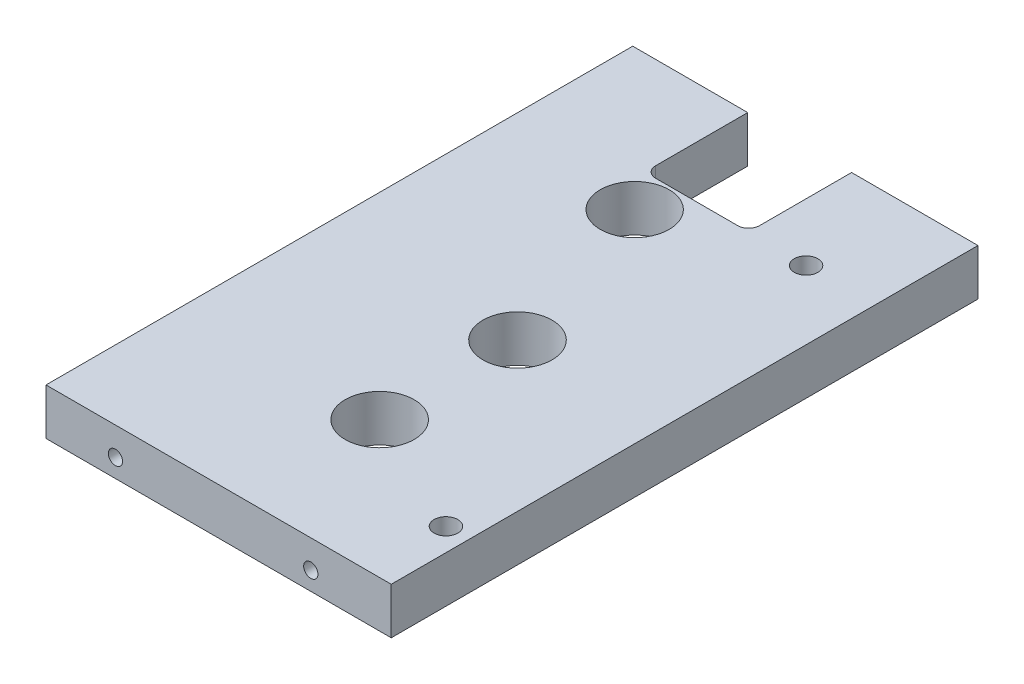
from build123d import *

# Parameters (mm, degrees)
SKETCH1_W           = 95.25
SKETCH1_H           = 12.8
BOSS_EXTRUDE1_DEPTH = 161.88
SKETCH1_3_R         = 3.1
CUT_EXTRUDE1_DEPTH  = 20.2
SKETCH1_4_R         = 2.395
CUT_EXTRUDE2_DEPTH  = 21.5
CUT_EXTRUDE3_REACH  = 14.8
SKETCH2_R           = 9.525
SKETCH2_R_2         = 3.265
SKETCH3_R           = 3.265
SKETCH3_R_2         = 9.525
CUT_EXTRUDE4_DEPTH  = 3.32
CUT_EXTRUDE5_START  = -17.25
SKETCH4_R           = 1.965
CUT_EXTRUDE5_DEPTH  = 17.25
SKETCH6_R           = 9.5
CUT_EXTRUDE6_DEPTH  = 13.8000001


with BuildPart() as part:
    # Sketch1 → Boss-Extrude1 (new body)
    with BuildSketch(Plane.XY):
        with Locations((-282.25, -82.5)):
            Rectangle(SKETCH1_W, SKETCH1_H)
    extrude(amount=BOSS_EXTRUDE1_DEPTH)

    # Sketch1_3 → Cut-Extrude1 (cut)
    with BuildSketch(Plane.XY):
        with Locations((-308, -82.5)):
            Circle(SKETCH1_3_R)
        with Locations((-257.2, -82.5)):
            Circle(SKETCH1_3_R)
    extrude(amount=CUT_EXTRUDE1_DEPTH, mode=Mode.SUBTRACT)

    # Sketch1_4 → Cut-Extrude2 (cut)
    with BuildSketch(Plane.XY):
        with Locations((-320.5, -82.5)):
            Circle(SKETCH1_4_R)
        with Locations((-244.2, -82.5)):
            Circle(SKETCH1_4_R)
    extrude(amount=CUT_EXTRUDE2_DEPTH, mode=Mode.SUBTRACT)

    # Sketch2 → Cut-Extrude3 (cut, up to next)
    with BuildSketch(Plane(origin=(0, -76.1, 0), x_dir=(-1, 0, 0), z_dir=(0, 1, 0)), mode=Mode.PRIVATE) as cut_extrude3_sk1:
        with Locations((275.57, 86.105)):
            Circle(SKETCH2_R)
    cut_extrude3_tool1 = extrude(cut_extrude3_sk1.sketch, amount=-CUT_EXTRUDE3_REACH, mode=Mode.PRIVATE) & part.part
    add(cut_extrude3_tool1.solids().sort_by_distance((-275.57, -76.1, 86.105))[0], mode=Mode.SUBTRACT)
    # Sketch2 → Cut-Extrude3 (cut, up to next)
    with BuildSketch(Plane(origin=(0, -76.1, 0), x_dir=(-1, 0, 0), z_dir=(0, 1, 0)), mode=Mode.PRIVATE) as cut_extrude3_sk2:
        with Locations((275.57, 124.135)):
            Circle(SKETCH2_R)
    cut_extrude3_tool2 = extrude(cut_extrude3_sk2.sketch, amount=-CUT_EXTRUDE3_REACH, mode=Mode.PRIVATE) & part.part
    add(cut_extrude3_tool2.solids().sort_by_distance((-275.57, -76.1, 124.135))[0], mode=Mode.SUBTRACT)
    # Sketch2 → Cut-Extrude3 (cut, up to next)
    with BuildSketch(Plane(origin=(0, -76.1, 0), x_dir=(-1, 0, 0), z_dir=(0, 1, 0)), mode=Mode.PRIVATE) as cut_extrude3_sk3:
        with Locations((253.55, 28.505)):
            Circle(SKETCH2_R_2)
    cut_extrude3_tool3 = extrude(cut_extrude3_sk3.sketch, amount=-CUT_EXTRUDE3_REACH, mode=Mode.PRIVATE) & part.part
    add(cut_extrude3_tool3.solids().sort_by_distance((-253.55, -76.1, 28.505))[0], mode=Mode.SUBTRACT)
    # Sketch2 → Cut-Extrude3 (cut, up to next)
    with BuildSketch(Plane(origin=(0, -76.1, 0), x_dir=(-1, 0, 0), z_dir=(0, 1, 0)), mode=Mode.PRIVATE) as cut_extrude3_sk4:
        with Locations((240.925, 140.49)):
            Circle(SKETCH2_R_2)
    cut_extrude3_tool4 = extrude(cut_extrude3_sk4.sketch, amount=-CUT_EXTRUDE3_REACH, mode=Mode.PRIVATE) & part.part
    add(cut_extrude3_tool4.solids().sort_by_distance((-240.925, -76.1, 140.49))[0], mode=Mode.SUBTRACT)
    # Sketch2 → Cut-Extrude3 (cut, up to next)
    with BuildSketch(Plane(origin=(0, -76.1, 0), x_dir=(-1, 0, 0), z_dir=(0, 1, 0)), mode=Mode.PRIVATE) as cut_extrude3_sk5:
        with BuildLine():
            Line((269.505, 25.4), (269.505, 0))
            Line((269.505, 0), (298.155, 0))
            Line((298.155, 0), (298.155, 25.4))
            ThreePointArc((298.155, 25.4), (297.276320344, 27.521320344), (295.155, 28.4))
            Line((295.155, 28.4), (272.505, 28.4))
            ThreePointArc((272.505, 28.4), (270.383679656, 27.521320344), (269.505, 25.4))
        make_face()
    cut_extrude3_tool5 = extrude(cut_extrude3_sk5.sketch, amount=-CUT_EXTRUDE3_REACH, mode=Mode.PRIVATE) & part.part
    add(cut_extrude3_tool5.solids().sort_by_distance((-283.83, -76.1, 14.135461))[0], mode=Mode.SUBTRACT)

    # Sketch3 → Cut-Extrude4 (cut)
    with BuildSketch(Plane.XZ.offset(88.9)):
        with Locations((-240.925, 140.49)):
            Circle(SKETCH3_R)
        with Locations((-253.55, 28.505)):
            Circle(SKETCH3_R_2)
    extrude(amount=-CUT_EXTRUDE4_DEPTH, mode=Mode.SUBTRACT)

    # Sketch4 → Cut-Extrude5 (cut)
    with BuildSketch(Plane.XY.offset(161.88).offset(CUT_EXTRUDE5_START)):
        with Locations((-256.825, -83.83)):
            Circle(SKETCH4_R)
        with Locations((-310.715, -83.83)):
            Circle(SKETCH4_R)
    extrude(amount=CUT_EXTRUDE5_DEPTH, mode=Mode.SUBTRACT)

    # Sketch6 → Cut-Extrude6 (cut, through all)
    with BuildSketch(Plane(origin=(0, -76.1, 0), x_dir=(-1, 0, 0), z_dir=(0, 1, 0))):
        with Locations((290.57, 38.77)):
            Circle(SKETCH6_R)
    extrude(amount=-CUT_EXTRUDE6_DEPTH, mode=Mode.SUBTRACT)


solid = part.part
